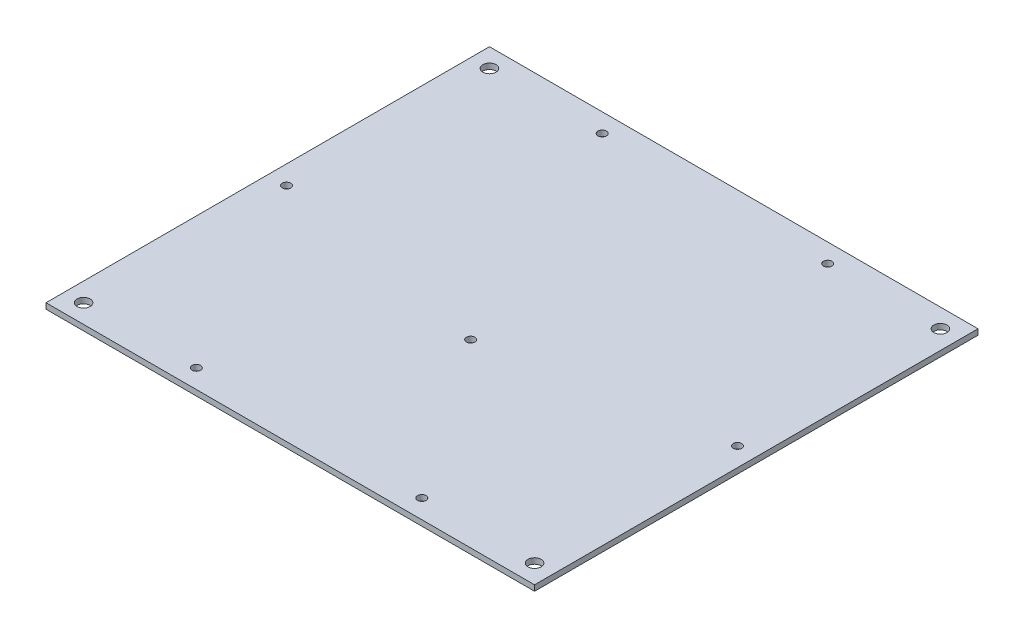
from build123d import *

# Parameters (mm, degrees)
SKETCH_1_W         = 260
SKETCH_1_H         = 236
SKETCH_1_R         = 2.25
SKETCH_1_R_2       = 3.5
EXTRUDE_1_DEPTH    = 3
SKETCH1_R          = 2.25
CUT_EXTRUDE1_DEPTH = 4


with BuildPart() as part:
    # Эскиз1 → Бобышка-Вытянуть1 (new body)
    with BuildSketch(Plane(origin=(0, 0, 0), x_dir=(1, 0, 0), z_dir=(0, 1, 0))):
        with Locations((130, 118)):
            Rectangle(SKETCH_1_W, SKETCH_1_H)
        with Locations((10, 118)):
            Circle(SKETCH_1_R, mode=Mode.SUBTRACT)
        with Locations((250, 118)):
            Circle(SKETCH_1_R, mode=Mode.SUBTRACT)
        with Locations((70, 226)):
            Circle(SKETCH_1_R, mode=Mode.SUBTRACT)
        with Locations((190, 226)):
            Circle(SKETCH_1_R, mode=Mode.SUBTRACT)
        with Locations((70, 10)):
            Circle(SKETCH_1_R, mode=Mode.SUBTRACT)
        with Locations((190, 10)):
            Circle(SKETCH_1_R, mode=Mode.SUBTRACT)
        with Locations((10, 226)):
            Circle(SKETCH_1_R_2, mode=Mode.SUBTRACT)
        with Locations((250, 226)):
            Circle(SKETCH_1_R_2, mode=Mode.SUBTRACT)
        with Locations((250, 10)):
            Circle(SKETCH_1_R_2, mode=Mode.SUBTRACT)
        with Locations((10, 10)):
            Circle(SKETCH_1_R_2, mode=Mode.SUBTRACT)
    extrude(amount=EXTRUDE_1_DEPTH)

    # Sketch1 → Cut-Extrude1 (cut, through all)
    with BuildSketch(Plane(origin=(0, 3, 0), x_dir=(1, 0, 0), z_dir=(0, 1, 0))):
        with Locations((130, 96)):
            Circle(SKETCH1_R)
    extrude(amount=-CUT_EXTRUDE1_DEPTH, mode=Mode.SUBTRACT)


solid = part.part
